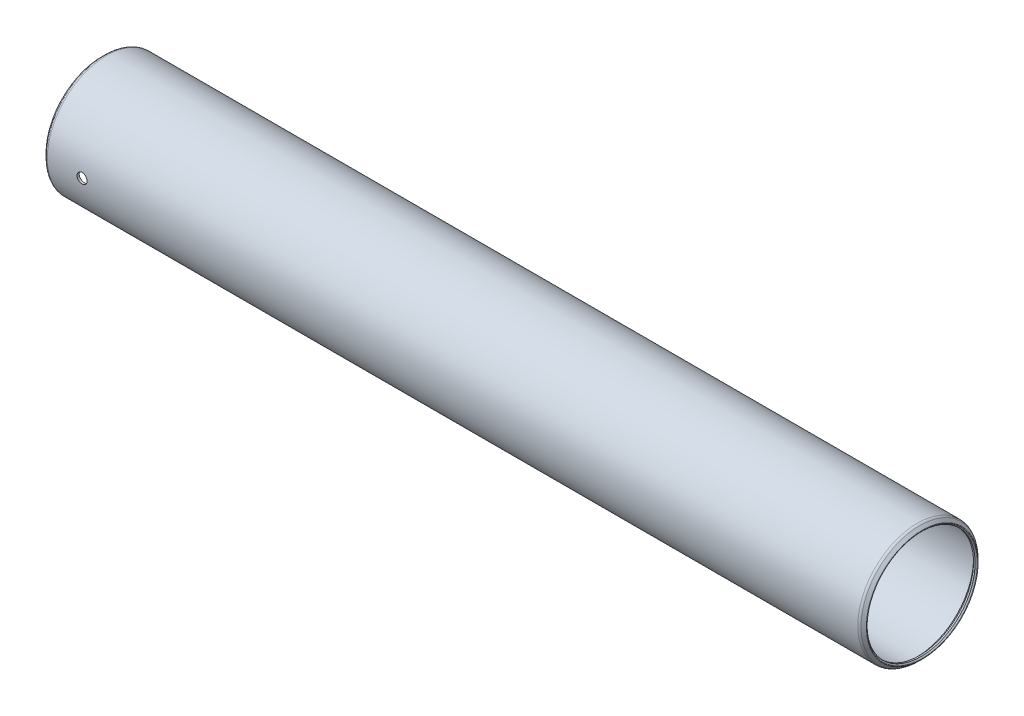
from build123d import *

# Parameters (mm, degrees)
SKETCH2_R          = 1.1938
CUT_EXTRUDE1_DEPTH = 14.1351


with BuildPart() as part:
    # Sketch1 → Revolve1 (revolve)
    with BuildSketch(Plane.XY):
        with BuildLine():
            Line((-0.639512806, 13.104562806), (-0.381, 12.84605))
            Line((-0.381, 12.84605), (0, 12.84605))
            Line((0, 12.84605), (0.762, 13.60805))
            Line((0.762, 13.60805), (192.8114, 13.60805))
            Line((192.8114, 13.60805), (193.5734, 12.84605))
            Line((193.5734, 12.84605), (193.9544, 12.84605))
            Line((193.9544, 12.84605), (194.212912806, 13.104562806))
            ThreePointArc((194.212912806, 13.104562806), (194.250110245, 13.194365367), (194.212912806, 13.284167928))
            Line((194.212912806, 13.284167928), (193.585165367, 13.911915367))
            ThreePointArc((193.585165367, 13.911915367), (193.337954775, 14.077096204), (193.04635, 14.1351))
            Line((193.04635, 14.1351), (0.52705, 14.1351))
            ThreePointArc((0.52705, 14.1351), (0.235445225, 14.077096204), (-0.011765367, 13.911915367))
            Line((-0.011765367, 13.911915367), (-0.639512806, 13.284167928))
            ThreePointArc((-0.639512806, 13.284167928), (-0.676710245, 13.194365367), (-0.639512806, 13.104562806))
        make_face()
    revolve(axis=Axis((193.5734, 0, 0), (-1, 0, 0)))

    # Sketch2 → Cut-Extrude1 (cut)
    with BuildSketch(Plane.XY):
        with Locations((8.763, 0)):
            Circle(SKETCH2_R)
    extrude(amount=CUT_EXTRUDE1_DEPTH, mode=Mode.SUBTRACT)


solid = part.part
